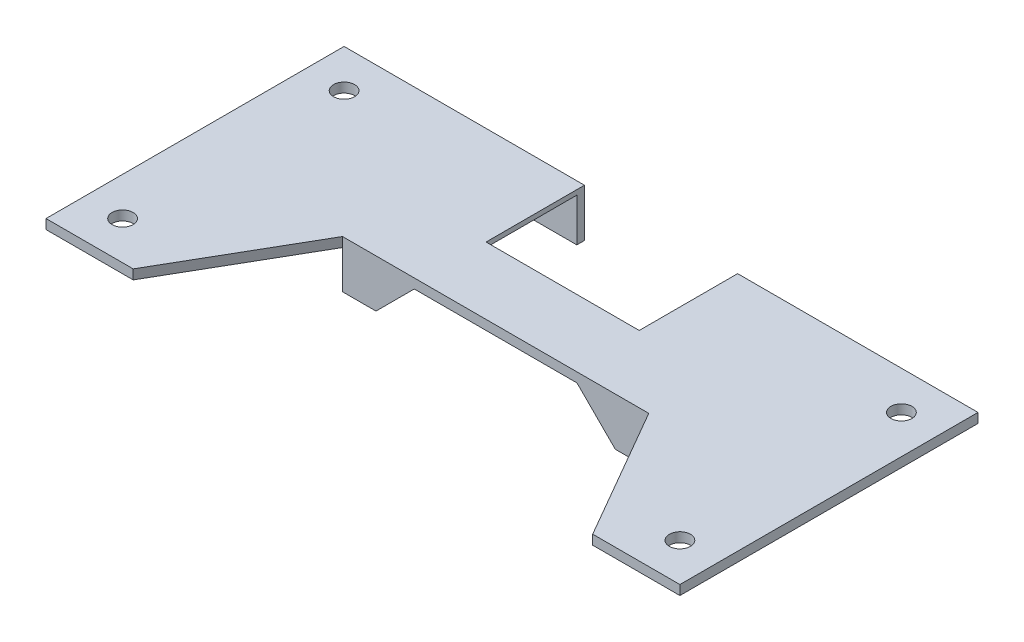
from build123d import *

# Parameters (mm, degrees)
SKETCH1_W             = 17.11
SKETCH1_H             = 31.14
SKETCH1_R             = 1.1
BOSS_EXTRUDE1_DEPTH   = 1
BOSS_EXTRUDE1_2_DEPTH = 1
SKETCH1_W_2           = 16
SKETCH1_H_2           = 7
BOSS_EXTRUDE1_3_DEPTH = 1
BOSS_EXTRUDE2_START   = 1
SKETCH1_3_W           = 8
SKETCH1_3_H           = 16.48
BOSS_EXTRUDE2_DEPTH   = 5
CHAMFER1_SIZE         = 4.5
CHAMFER2_SIZE         = 4.5
BOSS_EXTRUDE3_START   = 1
SKETCH1_4_W           = 8
SKETCH1_4_H           = 0.8
BOSS_EXTRUDE3_DEPTH   = 5
CHAMFER3_SIZE         = 8
CHAMFER3_SIZE2        = 13.856406461
CHAMFER4_SIZE         = 8
CHAMFER4_SIZE2        = 13.856406461


with BuildPart() as part:
    # Sketch1 → Boss-Extrude1 (new body)
    with BuildSketch(Plane(origin=(0, 0, 0), x_dir=(1, 0, 0), z_dir=(0, 1, 0))):
        with Locations((-31.94497183, -7.245370105)):
            Rectangle(SKETCH1_W, SKETCH1_H)
        with Locations((-36.49997183, -18.815370105)):
            Circle(SKETCH1_R, mode=Mode.SUBTRACT)
        with Locations((-36.49997183, 4.324629895)):
            Circle(SKETCH1_R, mode=Mode.SUBTRACT)
    extrude(amount=BOSS_EXTRUDE1_DEPTH)



with BuildPart() as body_2:
    # Sketch1 → Boss-Extrude1 2 (new body)
    with BuildSketch(Plane(origin=(0, 0, 0), x_dir=(1, 0, 0), z_dir=(0, 1, 0))):
        with Locations((17.16502817, -7.245370105)):
            Rectangle(SKETCH1_W, SKETCH1_H)
        with Locations((21.72002817, 4.324629895)):
            Circle(SKETCH1_R, mode=Mode.SUBTRACT)
        with Locations((21.72002817, -18.815370105)):
            Circle(SKETCH1_R, mode=Mode.SUBTRACT)
    extrude(amount=BOSS_EXTRUDE1_2_DEPTH)


with BuildPart() as body_3:
    # Sketch1 → Boss-Extrude1 3 (new body)
    with BuildSketch(Plane(origin=(0, 0, 0), x_dir=(1, 0, 0), z_dir=(0, 1, 0))):
        with Locations((-7.38997183, -5.455370105)):
            Rectangle(SKETCH1_W_2, SKETCH1_H_2)
    extrude(amount=BOSS_EXTRUDE1_3_DEPTH)


with BuildPart() as part_1:
    add(part.part)

    add(body_2.part)  # Boss-Extrude2 merges body 2

    add(body_3.part)  # Boss-Extrude2 merges body 3
    # Sketch1_3 → Boss-Extrude2 (add)
    with BuildSketch(Plane(origin=(0, 0, 0), x_dir=(1, 0, 0), z_dir=(0, 1, 0)).offset(BOSS_EXTRUDE2_START)):
        with Locations((-19.38997183, -0.715370105)):
            Rectangle(SKETCH1_3_W, SKETCH1_3_H)
        with Locations((4.61002817, -0.715370105)):
            Rectangle(SKETCH1_3_W, SKETCH1_3_H)
    extrude(amount=-BOSS_EXTRUDE2_DEPTH)

    # Chamfer1
    chamfer1_edges = [part_1.edges().sort_by_distance(p)[0] for p in [
        (0.61002817, -4, 0.715370105),
    ]]
    chamfer(chamfer1_edges, length=CHAMFER1_SIZE)

    # Chamfer2
    chamfer2_edges = [part_1.edges().sort_by_distance(p)[0] for p in [
        (-15.38997183, -4, 0.715370105),
    ]]
    chamfer(chamfer2_edges, length=CHAMFER2_SIZE)

    # Sketch1_4 → Boss-Extrude3 (add)
    with BuildSketch(Plane(origin=(0, 0, 0), x_dir=(1, 0, 0), z_dir=(0, 1, 0)).offset(BOSS_EXTRUDE3_START)):
        with Locations((-19.38997183, 7.924629895)):
            Rectangle(SKETCH1_4_W, SKETCH1_4_H)
        with Locations((4.61002817, 7.924629895)):
            Rectangle(SKETCH1_4_W, SKETCH1_4_H)
    extrude(amount=-BOSS_EXTRUDE3_DEPTH)

    # Chamfer3
    chamfer3_edges = [part_1.edges().sort_by_distance(p)[0] for p in [
        (-23.38997183, 0.5, 22.815370105),
    ]]
    chamfer3_side = [part_1.faces().sort_by_distance(p)[0] for p in [
        (-31.94497183, 0.5, 22.815370105),
    ]]
    chamfer(chamfer3_edges, length=CHAMFER3_SIZE, length2=CHAMFER3_SIZE2, reference=chamfer3_side[0])

    # Chamfer4
    chamfer4_edges = [part_1.edges().sort_by_distance(p)[0] for p in [
        (8.61002817, 0.5, 22.815370105),
    ]]
    chamfer4_side = [part_1.faces().sort_by_distance(p)[0] for p in [
        (17.16502817, 0.5, 22.815370105),
    ]]
    chamfer(chamfer4_edges, length=CHAMFER4_SIZE, length2=CHAMFER4_SIZE2, reference=chamfer4_side[0])


solid = part_1.part
